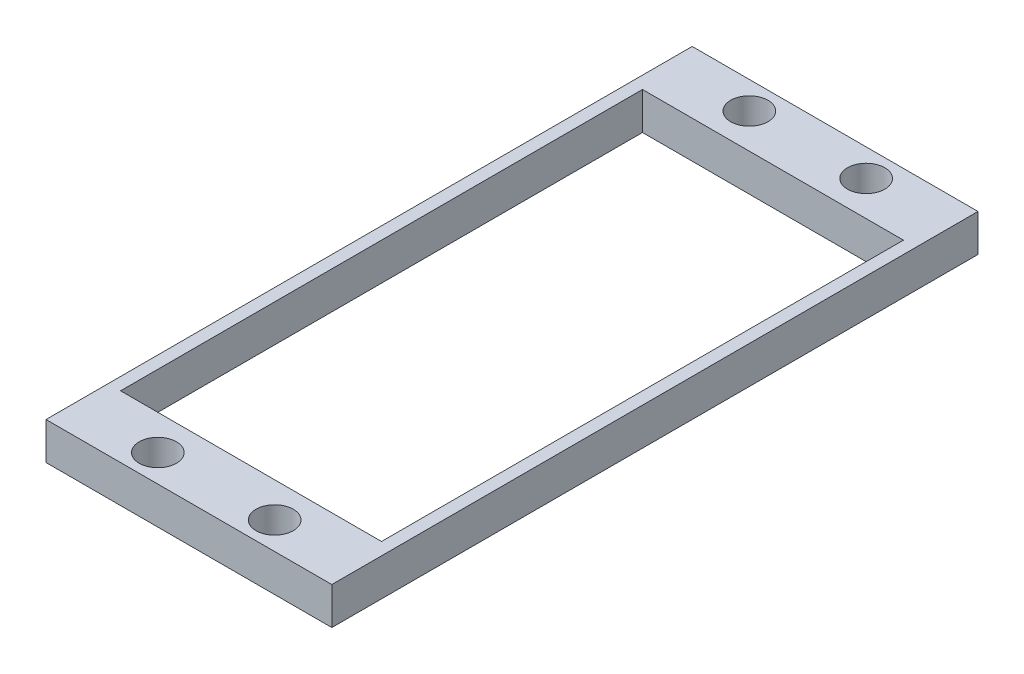
from build123d import *

# Parameters (mm, degrees)
SKETCH_1_R      = 1.5
SKETCH_1_W      = 21
SKETCH_1_H      = 42
EXTRUDE_1_DEPTH = 3


with BuildPart() as part:
    # 草圖1 → 填料-伸長1 (new body)
    with BuildSketch(Plane(origin=(0, 0, 0), x_dir=(1, 0, 0), z_dir=(0, 1, 0))):
        Polygon((11.5, 22), (11.5, -22), (11.5, -26), (-11.5, -26), (-11.5, -22), (-11.5, 22), (-11.5, 26), (11.5, 26), align=None)
        with Locations((-4.7, 23.8)):
            Circle(SKETCH_1_R, mode=Mode.SUBTRACT)
        with Locations((4.7, 23.8)):
            Circle(SKETCH_1_R, mode=Mode.SUBTRACT)
        with Locations((4.7, -23.8)):
            Circle(SKETCH_1_R, mode=Mode.SUBTRACT)
        with Locations((-4.7, -23.8)):
            Circle(SKETCH_1_R, mode=Mode.SUBTRACT)
        Rectangle(SKETCH_1_W, SKETCH_1_H, mode=Mode.SUBTRACT)
    extrude(amount=EXTRUDE_1_DEPTH)


solid = part.part
